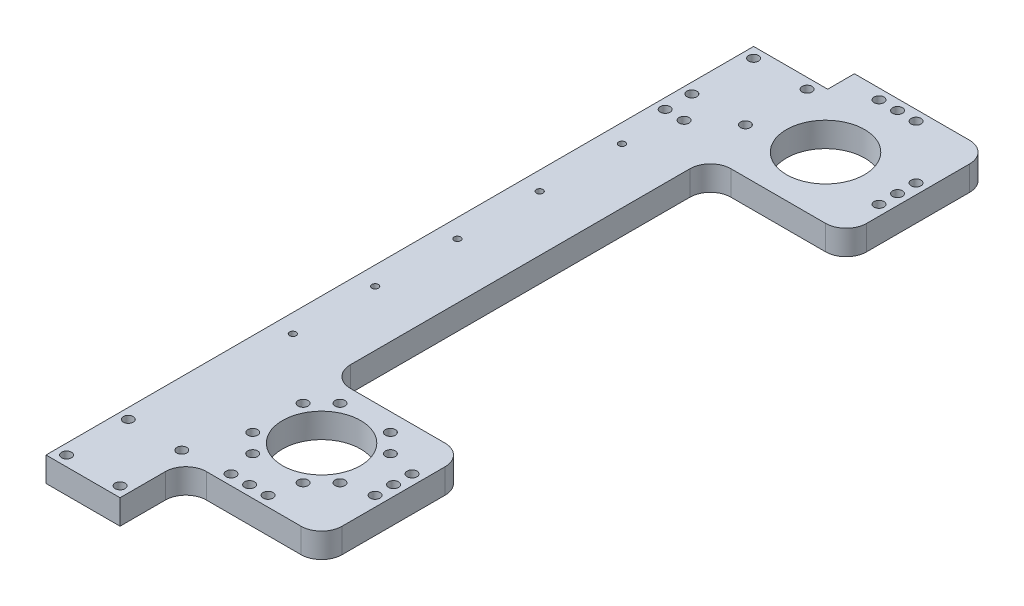
from build123d import *

# Parameters (mm, degrees)
SKETCH1_W            = 18
SKETCH1_H            = 172
BOSS_EXTRUDE1_DEPTH  = 6
SKETCH3_W            = 35
SKETCH3_H            = 6
BOSS_EXTRUDE2_DEPTH  = 32.98
SKETCH2_R            = 9.5
CUT_EXTRUDE1_DEPTH   = 7
FILLET1_R            = 5
M2_TAPPED_HOLE1_D    = 1.6
M2_CLEARANCE_HOLE1_D = 2.4
M2_CLEARANCE_HOLE2_D = 2.4
M2_CLEARANCE_HOLE3_D = 2.4
M2_CLEARANCE_HOLE4_D = 2.4


with BuildPart() as part:
    # Sketch1 → Boss-Extrude1 (new body)
    with BuildSketch(Plane(origin=(0, 0, 0), x_dir=(1, 0, 0), z_dir=(0, 1, 0))):
        with Locations((9, 86)):
            Rectangle(SKETCH1_W, SKETCH1_H)
    extrude(amount=BOSS_EXTRUDE1_DEPTH)

    # Sketch3 → Boss-Extrude2 (add)
    with BuildSketch(Plane(origin=(18, 0, 0), x_dir=(0, 0, -1), z_dir=(1, 0, 0))):
        with Locations((33.5, 3)):
            Rectangle(SKETCH3_W, SKETCH3_H)
        with Locations((161, 3)):
            Rectangle(SKETCH3_W, SKETCH3_H)
    extrude(amount=BOSS_EXTRUDE2_DEPTH)

    # Sketch2 → Cut-Extrude1 (cut, through all)
    with BuildSketch(Plane(origin=(0, 6, 0), x_dir=(1, 0, 0), z_dir=(0, 1, 0))):
        with Locations(Location((30.98, 36, 0), (0, 0, 270))):  # turned: the seam where the file's is
            Circle(SKETCH2_R)
        with Locations(Location((30.98, 158.5, 0), (0, 0, 270))):  # turned: the seam where the file's is
            Circle(SKETCH2_R)
    extrude(amount=-CUT_EXTRUDE1_DEPTH, mode=Mode.SUBTRACT)

    # Fillet1
    fillet1_edges = [part.edges().sort_by_distance(p)[0] for p in [
        (18, 3, -51),
        (50.98, 3, -51),
        (50.98, 3, -178.5),
        (50.98, 3, -143.5),
        (18, 3, -143.5),
        (50.98, 3, -16),
        (18, 3, -16),
    ]]
    fillet(fillet1_edges, radius=FILLET1_R)

    # M2 Tapped Hole1 (through all)
    with Locations(Plane(origin=(0, 6, 0), x_dir=(-1, 0, 0), z_dir=(0, 1, 0))):
        with Locations((-4.5, -55.5), (-4.5, -75.5), (-4.5, -95.5), (-4.5, -115.5), (-4.5, -135.5)):
            Hole(M2_TAPPED_HOLE1_D / 2)

    # M2 Clearance Hole1 (through all)
    with Locations(Plane(origin=(48.48, 6, -40.5), x_dir=(0, 0, 1), z_dir=(0, 1, 0))):
        with Locations((0, 0), (22, -22), (22, -17.5), (22, -13), (4.5, 0), (9, 0), (-135.5, -22), (-135.5, -17.5), (-135.5, -13), (-113.5, 0), (-118, 0), (-122.5, 0)):
            Hole(M2_CLEARANCE_HOLE1_D / 2)

    # M2 Clearance Hole2 (through all)
    with Locations(Plane(origin=(0, 6, 0), x_dir=(-1, 0, 0), z_dir=(0, 1, 0))):
        with Locations((-2.5, -2.5), (-15.5, -2.5), (-15.5, -17.5), (-2.5, -17.5), (-15.5, -154.5), (-15.5, -169.5), (-2.5, -154.5), (-2.5, -169.5)):
            Hole(M2_CLEARANCE_HOLE2_D / 2)

    # M2 Clearance Hole3 (through all)
    with Locations(Plane(origin=(0, 6, 0), x_dir=(-1, 0, 0), z_dir=(0, 1, 0))):
        with Locations((-2.5, -148), (-7.1, -148)):
            Hole(M2_CLEARANCE_HOLE3_D / 2)

    # M2 Clearance Hole4 (through all)
    with Locations(Plane(origin=(0, 6, 0), x_dir=(-1, 0, 0), z_dir=(0, 1, 0))):
        with Locations((-20.371188804, -29.875), (-24.855, -25.391188804), (-20.371188804, -42.125), (-24.855, -46.608811196), (-37.105, -46.608811196), (-41.588811196, -42.125), (-41.588811196, -29.875), (-37.105, -25.391188804)):
            Hole(M2_CLEARANCE_HOLE4_D / 2)


solid = part.part
